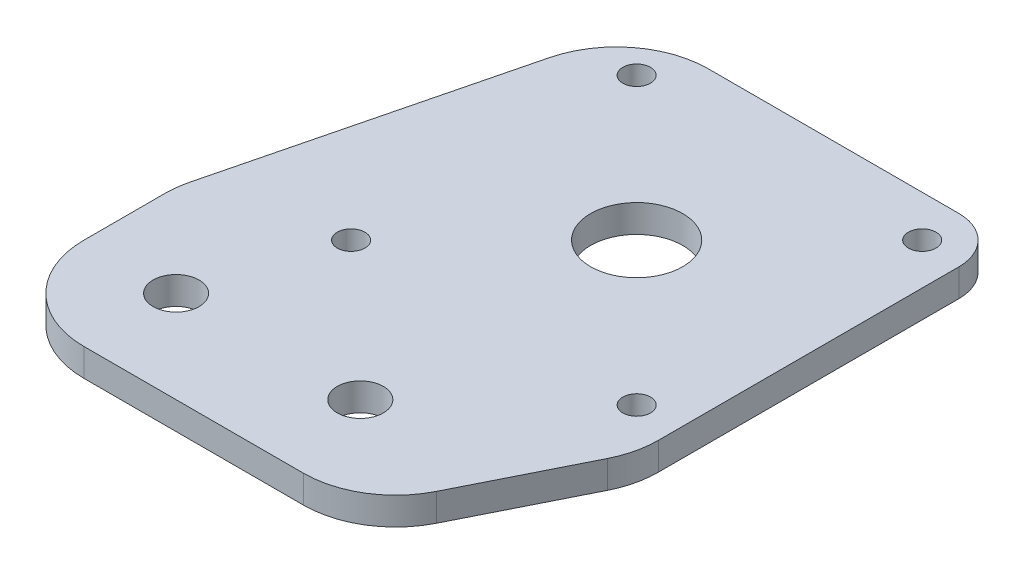
from build123d import *

# Parameters (mm, degrees)
SKETCH1_R            = 5
BOSS_EXTRUDE1_DEPTH  = 3
SKETCH2_R            = 1.5
CUT_EXTRUDE1_DEPTH   = 4
LPATTERN1_COUNT      = 2
LPATTERN1_PITCH      = 31
LPATTERN1_COUNT_DIR2 = 2
LPATTERN1_PITCH_DIR2 = 31
SKETCH3_R            = 2.5
CUT_EXTRUDE2_DEPTH   = 4
LPATTERN2_COUNT      = 2
LPATTERN2_PITCH      = 20
FILLET1_R            = 10
FILLET2_R            = 5


with BuildPart() as part:
    # Sketch1 → Boss-Extrude1 (new body)
    with BuildSketch(Plane(origin=(0, 0, 0), x_dir=(1, 0, 0), z_dir=(0, 1, 0))):
        Polygon((20, -20), (10, -40), (-30, -40), (-30, -20), (-20, 20), (20, 20), align=None)
        Circle(SKETCH1_R, mode=Mode.SUBTRACT)
    extrude(amount=BOSS_EXTRUDE1_DEPTH)

    # Sketch2 → Cut-Extrude1 (cut, through all)
    with BuildSketch(Plane(origin=(0, 3, 0), x_dir=(1, 0, 0), z_dir=(0, 1, 0))):
        with Locations((-15.5, 15.5)):
            Circle(SKETCH2_R)
    cut_extrude1 = extrude(amount=-CUT_EXTRUDE1_DEPTH, mode=Mode.SUBTRACT)

    # LPattern1: Cut-Extrude1 2 × 2
    with Locations(*[(i * LPATTERN1_PITCH, 0, j * LPATTERN1_PITCH_DIR2) for i in range(LPATTERN1_COUNT) for j in range(LPATTERN1_COUNT_DIR2) if (i, j) != (0, 0)]):
        add(cut_extrude1, mode=Mode.SUBTRACT)

    # Sketch3 → Cut-Extrude2 (cut, through all)
    with BuildSketch(Plane(origin=(0, 3, 0), x_dir=(1, 0, 0), z_dir=(0, 1, 0))):
        with Locations((-20, -30)):
            Circle(SKETCH3_R)
    cut_extrude2 = extrude(amount=-CUT_EXTRUDE2_DEPTH, mode=Mode.SUBTRACT)

    # LPattern2: Cut-Extrude2 ×2
    with Locations(*[(i * LPATTERN2_PITCH, 0, 0) for i in range(1, LPATTERN2_COUNT)]):
        add(cut_extrude2, mode=Mode.SUBTRACT)

    # Fillet1
    fillet1_edges = [part.edges().sort_by_distance(p)[0] for p in [
        (-30, 1.5, 40),
        (-30, 1.5, 20),
        (-20, 1.5, -20),
        (20, 1.5, 20),
        (10, 1.5, 40),
    ]]
    fillet(fillet1_edges, radius=FILLET1_R)

    # Fillet2
    fillet2_edges = [part.edges().sort_by_distance(p)[0] for p in [
        (20, 1.5, -20),
    ]]
    fillet(fillet2_edges, radius=FILLET2_R)


solid = part.part
